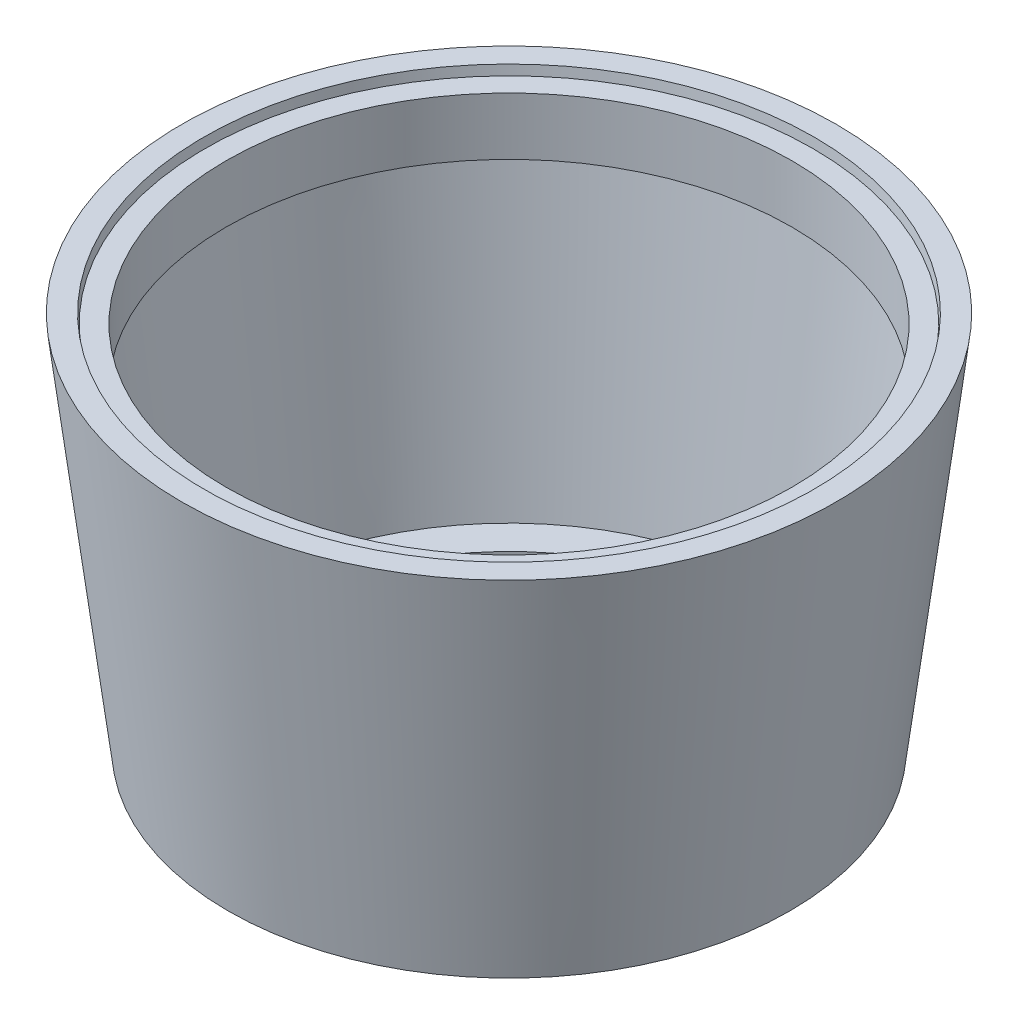
from build123d import *


with BuildPart() as part:
    # 草图1 → 旋转1 (revolve)
    with BuildSketch(Plane.XY):
        Polygon((-120.220130321, 0), (4.934362747, 0), (129.808523439, 1017.018424575), (70.219494021, 1017.018424575), (67.100908272, 991.619581867), (10.443995457, 991.619581867), (10.443995457, 836.737393315), (74.304215032, 836.737393315), (-26.715234545, 14), (-120.220130321, 14), align=None)
    revolve(axis=Axis((-752, 0, 0), (0, 1, 0)))


solid = part.part
